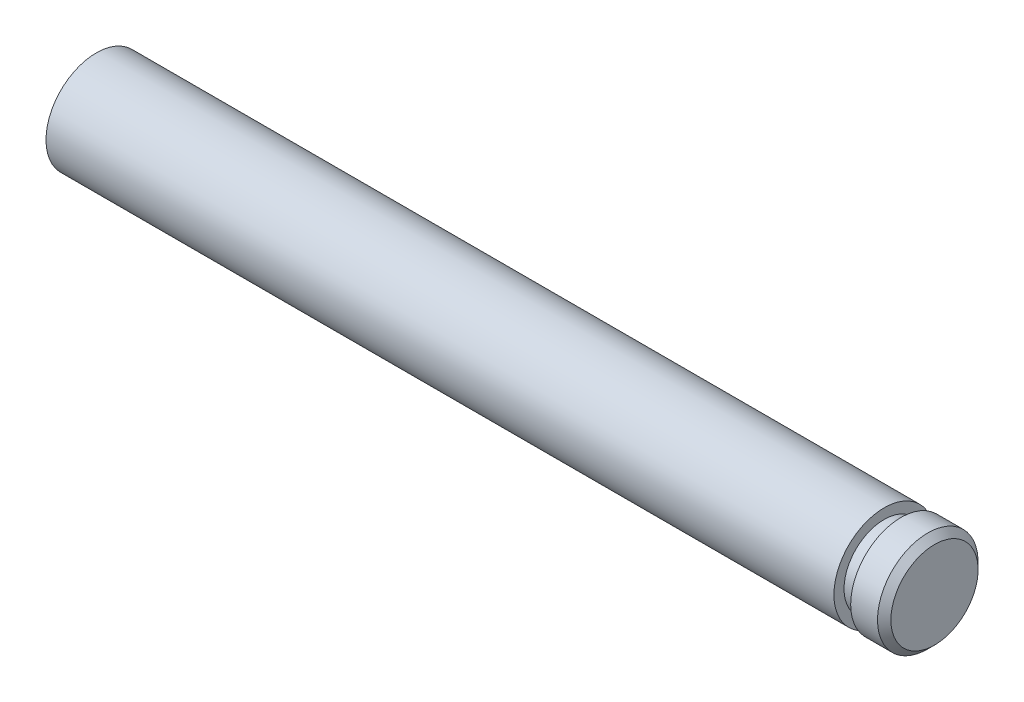
from build123d import *

# Parameters (mm, degrees)
CHAFL_N1_SIZE = 0.2


with BuildPart() as part:
    # Croquis1 → Revolución1 (revolve)
    with BuildSketch(Plane(origin=(0, 0, 0), x_dir=(1, 0, 0), z_dir=(0, 1, 0))):
        Polygon((0, 0), (25, 0), (25, 1.5), (24, 1.5), (24, 1.198324022), (23.5, 1.198324022), (23.5, 1.5), (0, 1.5), align=None)
    revolve(axis=Axis((0, 0, 0), (1, 0, 0)))

    # Chaflán1
    chafl_n1_edges = [part.edges().sort_by_distance(p)[0] for p in [
        (25, 0, 1.5),
    ]]
    chamfer(chafl_n1_edges, length=CHAFL_N1_SIZE)


solid = part.part
